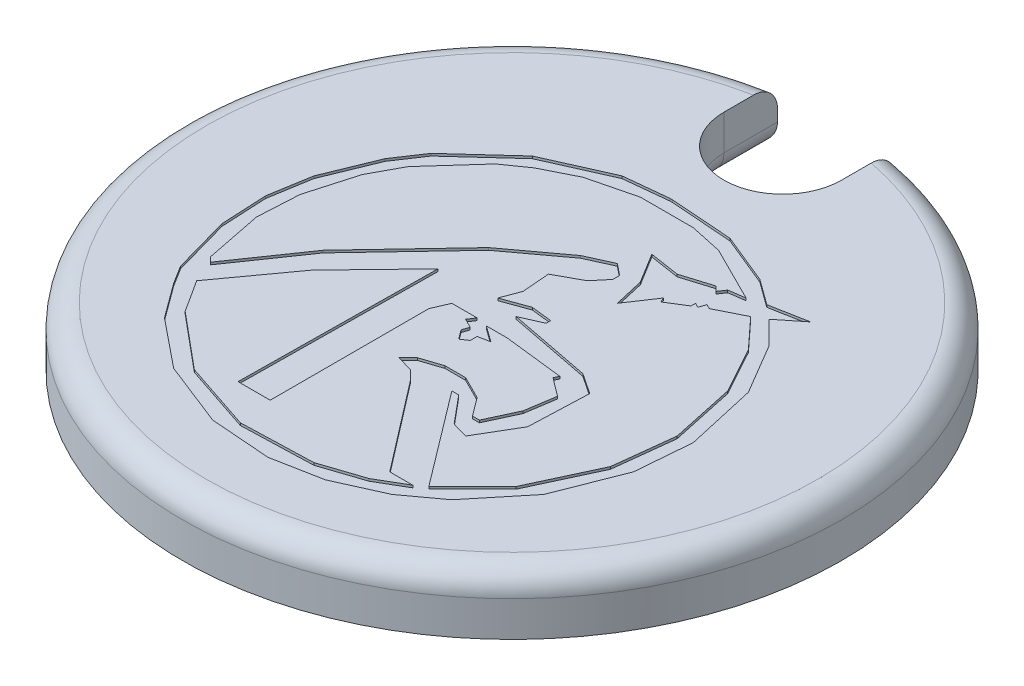
from build123d import *

# Parameters (mm, degrees)
SKETCH2_R               = 35.56
BOSS_EXTRUDE1_DEPTH     = 6.35
CUT_EXTRUDE2_DEPTH      = 1
CUT_EXTRUDE2_DEPTH_BACK = 7.35
FILLET2_R               = 2.54
BOSS_EXTRUDE5_DEPTH     = 5.334
CUT_EXTRUDE3_DEPTH      = 0.254
FILLET3_R               = 2.54


with BuildPart() as part:
    # Sketch2 → Boss-Extrude1 (new body)
    with BuildSketch(Plane(origin=(0, 0, 0), x_dir=(1, 0, 0), z_dir=(0, 1, 0))):
        Circle(SKETCH2_R)
    extrude(amount=BOSS_EXTRUDE1_DEPTH)

    # Sketch5 → Cut-Extrude2 (cut, two sides)
    with BuildSketch(Plane.XZ) as cut_extrude2_sk:
        with BuildLine():
            Line((6.35, -34.988442377), (6.35, -29.21))
            ThreePointArc((6.35, -29.21), (0, -22.86), (-6.35, -29.21))
            Line((-6.35, -29.21), (-6.35, -34.988442377))
            ThreePointArc((-6.35, -34.988442377), (0, -35.56), (6.35, -34.988442377))
        make_face()
    extrude(amount=CUT_EXTRUDE2_DEPTH, mode=Mode.SUBTRACT)
    extrude(cut_extrude2_sk.sketch, amount=-CUT_EXTRUDE2_DEPTH_BACK, mode=Mode.SUBTRACT)

    # Fillet2
    fillet2_edges = [part.edges().sort_by_distance(p)[0] for p in [
        (-6.35, 0, -32.099221189),
        (0, 0, -22.86),
        (6.35, 0, -32.099221189),
    ]]
    fillet(fillet2_edges, radius=FILLET2_R)

    # Sketch12 → Boss-Extrude5 (add)
    with BuildSketch(Plane(origin=(0, 6.35, 0), x_dir=(1, 0, 0), z_dir=(0, 1, 0))):
        Polygon((-23.011064279, -8.288364013), (-21.274736154, -14.489535888), (-20.034501779, -16.473910888), (-17.305986154, -20.194614013), (-12.097001779, -24.411410888), (-5.151689279, -27.139926513), (1.297529471, -27.636020263), (6.506513846, -26.643832763), (11.467451346, -24.411410888), (15.188154471, -21.682895263), (19.652998221, -16.225864013), (22.381513846, -9.280551513), (22.877607596, -3.327426513), (21.141279471, 4.362026612), (17.916670096, 9.819057862), (15.436201346, 12.299526612), (17.916670096, 14.283901612), (13.947920096, 13.539760987), (11.219404471, 15.524135987), (5.762373221, 17.756557862), (-0.934892404, 18.252651612), (-1.182939279, 18.252651612), (-5.895829904, 17.756557862), (-12.593095529, 14.779995362), (-18.298173654, 9.571010987), (-20.282548654, 6.594448487), (-22.514970529, 1.137417237), (-23.259111154, -3.327426513), align=None)
        Polygon((-13.833329904, -7.792270263), (-7.136168544, -0.855924569), (-7.384111154, -22.178989013), (-3.911454904, -22.178989013), (-3.911454904, -5.063754638), (-3.167314279, -3.327426513), (-0.438798654, -3.327426513), (-0.934892404, -4.071567138), (0.057295096, -4.567660888), (-0.190751779, -5.311801513), (0.553388846, -6.303989013), (1.297529471, -5.807895263), (1.297529471, -5.063754638), (2.537763846, -4.815707763), (0.801435721, -3.575473388), (3.033857596, -3.575473388), (9.483076346, -4.319614013), (9.235029471, -4.815707763), (11.219404471, -6.303989013), (10.723310721, -9.528598388), (9.235029471, -12.753207763), (8.490888846, -12.753207763), (7.002607596, -10.768832763), (4.522138846, -9.528598388), (2.289716971, -9.528598388), (0.057295096, -10.272739013), (-0.934892404, -11.264926513), (0.801435721, -11.761020263), (1.793623221, -12.753207763), (9.235029471, -22.427035888), (11.715498221, -22.427035888), (8.738935721, -24.163364013), (4.274091971, -25.651645263), (-3.415361154, -25.899692138), (-10.856767404, -23.419223388), (-16.809892404, -18.458285888), (-19.042314279, -14.985629638), align=None, mode=Mode.SUBTRACT)
        Polygon((-7.880204904, 15.524135987), (-2.919267404, 16.764370362), (-2.671220529, 16.764370362), (2.785810721, 16.764370362), (6.258466971, 16.020229737), (12.211591971, 13.043667237), (10.475263846, 12.795620362), (9.979170096, 12.051479737), (9.483076346, 12.547573487), (6.258466971, 11.555385987), (3.033857596, 12.051479737), (5.018232596, 8.826870362), (5.762373221, 5.602260987), (7.746748221, 8.578823487), (7.994795096, 8.082729737), (9.979170096, 9.322964112), (9.979170096, 9.819057862), (10.475263846, 9.571010987), (10.723310721, 10.315151612), (11.219404471, 10.067104737), (14.195966971, 11.555385987), (17.172529471, 8.330776612), (19.901045096, 3.369839112), (21.389326346, -3.575473388), (20.645185721, -10.024692138), (17.420576346, -16.970004638), (12.707685721, -21.682895263), (5.018232596, -11.512973388), (5.762373221, -11.512973388), (8.242841971, -14.489535888), (9.979170096, -14.985629638), (12.459638846, -10.768832763), (12.707685721, -4.319614013), (10.475263846, -2.831332763), (1.545576346, -1.095004638), (3.777998221, -0.102817138), (3.777998221, 0.393276612), (1.545576346, 0.641323487), (-1.182939279, -0.350864013), (-0.438798654, 1.633510987), (-0.686845529, 4.610073487), (2.041670096, 6.098354737), (3.281904471, 7.586635987), (3.281904471, 8.330776612), (2.041670096, 9.322964112), (-0.686845529, 8.082729737), (-6.391923654, 3.865932862), (-15.073564279, -5.311801513), (-20.034501779, -12.505160888), (-20.530595529, -12.009067138), (-21.770829904, -5.807895263), (-21.522783029, -1.343051513), (-20.034501779, 3.865932862), (-18.298173654, 7.090542237), (-13.833329904, 12.051479737), (-11.352861154, 13.787807862), align=None, mode=Mode.SUBTRACT)
        Polygon((-23.011064279, -8.288364013), (-21.274736154, -14.489535888), (-20.034501779, -16.473910888), (-17.305986154, -20.194614013), (-12.097001779, -24.411410888), (-5.151689279, -27.139926513), (1.297529471, -27.636020263), (6.506513846, -26.643832763), (11.467451346, -24.411410888), (15.188154471, -21.682895263), (19.652998221, -16.225864013), (22.381513846, -9.280551513), (22.877607596, -3.327426513), (21.141279471, 4.362026612), (17.916670096, 9.819057862), (15.436201346, 12.299526612), (17.916670096, 14.283901612), (13.947920096, 13.539760987), (11.219404471, 15.524135987), (5.762373221, 17.756557862), (-0.934892404, 18.252651612), (-1.182939279, 18.252651612), (-5.895829904, 17.756557862), (-12.593095529, 14.779995362), (-18.298173654, 9.571010987), (-20.282548654, 6.594448487), (-22.514970529, 1.137417237), (-23.259111154, -3.327426513), align=None)
        Polygon((-13.833329904, -7.792270263), (-7.136168544, -0.855924569), (-7.384111154, -22.178989013), (-3.911454904, -22.178989013), (-3.911454904, -5.063754638), (-3.167314279, -3.327426513), (-0.438798654, -3.327426513), (-0.934892404, -4.071567138), (0.057295096, -4.567660888), (-0.190751779, -5.311801513), (0.553388846, -6.303989013), (1.297529471, -5.807895263), (1.297529471, -5.063754638), (2.537763846, -4.815707763), (0.801435721, -3.575473388), (3.033857596, -3.575473388), (9.483076346, -4.319614013), (9.235029471, -4.815707763), (11.219404471, -6.303989013), (10.723310721, -9.528598388), (9.235029471, -12.753207763), (8.490888846, -12.753207763), (7.002607596, -10.768832763), (4.522138846, -9.528598388), (2.289716971, -9.528598388), (0.057295096, -10.272739013), (-0.934892404, -11.264926513), (0.801435721, -11.761020263), (1.793623221, -12.753207763), (9.235029471, -22.427035888), (11.715498221, -22.427035888), (8.738935721, -24.163364013), (4.274091971, -25.651645263), (-3.415361154, -25.899692138), (-10.856767404, -23.419223388), (-16.809892404, -18.458285888), (-19.042314279, -14.985629638), align=None, mode=Mode.SUBTRACT)
        Polygon((-7.880204904, 15.524135987), (-2.919267404, 16.764370362), (-2.671220529, 16.764370362), (2.785810721, 16.764370362), (6.258466971, 16.020229737), (12.211591971, 13.043667237), (10.475263846, 12.795620362), (9.979170096, 12.051479737), (9.483076346, 12.547573487), (6.258466971, 11.555385987), (3.033857596, 12.051479737), (5.018232596, 8.826870362), (5.762373221, 5.602260987), (7.746748221, 8.578823487), (7.994795096, 8.082729737), (9.979170096, 9.322964112), (9.979170096, 9.819057862), (10.475263846, 9.571010987), (10.723310721, 10.315151612), (11.219404471, 10.067104737), (14.195966971, 11.555385987), (17.172529471, 8.330776612), (19.901045096, 3.369839112), (21.389326346, -3.575473388), (20.645185721, -10.024692138), (17.420576346, -16.970004638), (12.707685721, -21.682895263), (5.018232596, -11.512973388), (5.762373221, -11.512973388), (8.242841971, -14.489535888), (9.979170096, -14.985629638), (12.459638846, -10.768832763), (12.707685721, -4.319614013), (10.475263846, -2.831332763), (1.545576346, -1.095004638), (3.777998221, -0.102817138), (3.777998221, 0.393276612), (1.545576346, 0.641323487), (-1.182939279, -0.350864013), (-0.438798654, 1.633510987), (-0.686845529, 4.610073487), (2.041670096, 6.098354737), (3.281904471, 7.586635987), (3.281904471, 8.330776612), (2.041670096, 9.322964112), (-0.686845529, 8.082729737), (-6.391923654, 3.865932862), (-15.073564279, -5.311801513), (-20.034501779, -12.505160888), (-20.530595529, -12.009067138), (-21.770829904, -5.807895263), (-21.522783029, -1.343051513), (-20.034501779, 3.865932862), (-18.298173654, 7.090542237), (-13.833329904, 12.051479737), (-11.352861154, 13.787807862), align=None, mode=Mode.SUBTRACT)
        Polygon((-23.011064279, -8.288364013), (-21.274736154, -14.489535888), (-20.034501779, -16.473910888), (-17.305986154, -20.194614013), (-12.097001779, -24.411410888), (-5.151689279, -27.139926513), (1.297529471, -27.636020263), (6.506513846, -26.643832763), (11.467451346, -24.411410888), (15.188154471, -21.682895263), (19.652998221, -16.225864013), (22.381513846, -9.280551513), (22.877607596, -3.327426513), (21.141279471, 4.362026612), (17.916670096, 9.819057862), (15.436201346, 12.299526612), (17.916670096, 14.283901612), (13.947920096, 13.539760987), (11.219404471, 15.524135987), (5.762373221, 17.756557862), (-0.934892404, 18.252651612), (-1.182939279, 18.252651612), (-5.895829904, 17.756557862), (-12.593095529, 14.779995362), (-18.298173654, 9.571010987), (-20.282548654, 6.594448487), (-22.514970529, 1.137417237), (-23.259111154, -3.327426513), align=None)
        Polygon((-13.833329904, -7.792270263), (-7.136168544, -0.855924569), (-7.384111154, -22.178989013), (-3.911454904, -22.178989013), (-3.911454904, -5.063754638), (-3.167314279, -3.327426513), (-0.438798654, -3.327426513), (-0.934892404, -4.071567138), (0.057295096, -4.567660888), (-0.190751779, -5.311801513), (0.553388846, -6.303989013), (1.297529471, -5.807895263), (1.297529471, -5.063754638), (2.537763846, -4.815707763), (0.801435721, -3.575473388), (3.033857596, -3.575473388), (9.483076346, -4.319614013), (9.235029471, -4.815707763), (11.219404471, -6.303989013), (10.723310721, -9.528598388), (9.235029471, -12.753207763), (8.490888846, -12.753207763), (7.002607596, -10.768832763), (4.522138846, -9.528598388), (2.289716971, -9.528598388), (0.057295096, -10.272739013), (-0.934892404, -11.264926513), (0.801435721, -11.761020263), (1.793623221, -12.753207763), (9.235029471, -22.427035888), (11.715498221, -22.427035888), (8.738935721, -24.163364013), (4.274091971, -25.651645263), (-3.415361154, -25.899692138), (-10.856767404, -23.419223388), (-16.809892404, -18.458285888), (-19.042314279, -14.985629638), align=None, mode=Mode.SUBTRACT)
        Polygon((-7.880204904, 15.524135987), (-2.919267404, 16.764370362), (-2.671220529, 16.764370362), (2.785810721, 16.764370362), (6.258466971, 16.020229737), (12.211591971, 13.043667237), (10.475263846, 12.795620362), (9.979170096, 12.051479737), (9.483076346, 12.547573487), (6.258466971, 11.555385987), (3.033857596, 12.051479737), (5.018232596, 8.826870362), (5.762373221, 5.602260987), (7.746748221, 8.578823487), (7.994795096, 8.082729737), (9.979170096, 9.322964112), (9.979170096, 9.819057862), (10.475263846, 9.571010987), (10.723310721, 10.315151612), (11.219404471, 10.067104737), (14.195966971, 11.555385987), (17.172529471, 8.330776612), (19.901045096, 3.369839112), (21.389326346, -3.575473388), (20.645185721, -10.024692138), (17.420576346, -16.970004638), (12.707685721, -21.682895263), (5.018232596, -11.512973388), (5.762373221, -11.512973388), (8.242841971, -14.489535888), (9.979170096, -14.985629638), (12.459638846, -10.768832763), (12.707685721, -4.319614013), (10.475263846, -2.831332763), (1.545576346, -1.095004638), (3.777998221, -0.102817138), (3.777998221, 0.393276612), (1.545576346, 0.641323487), (-1.182939279, -0.350864013), (-0.438798654, 1.633510987), (-0.686845529, 4.610073487), (2.041670096, 6.098354737), (3.281904471, 7.586635987), (3.281904471, 8.330776612), (2.041670096, 9.322964112), (-0.686845529, 8.082729737), (-6.391923654, 3.865932862), (-15.073564279, -5.311801513), (-20.034501779, -12.505160888), (-20.530595529, -12.009067138), (-21.770829904, -5.807895263), (-21.522783029, -1.343051513), (-20.034501779, 3.865932862), (-18.298173654, 7.090542237), (-13.833329904, 12.051479737), (-11.352861154, 13.787807862), align=None, mode=Mode.SUBTRACT)
        Polygon((-23.011064279, -8.288364013), (-21.274736154, -14.489535888), (-20.034501779, -16.473910888), (-17.305986154, -20.194614013), (-12.097001779, -24.411410888), (-5.151689279, -27.139926513), (1.297529471, -27.636020263), (6.506513846, -26.643832763), (11.467451346, -24.411410888), (15.188154471, -21.682895263), (19.652998221, -16.225864013), (22.381513846, -9.280551513), (22.877607596, -3.327426513), (21.141279471, 4.362026612), (17.916670096, 9.819057862), (15.436201346, 12.299526612), (17.916670096, 14.283901612), (13.947920096, 13.539760987), (11.219404471, 15.524135987), (5.762373221, 17.756557862), (-0.934892404, 18.252651612), (-1.182939279, 18.252651612), (-5.895829904, 17.756557862), (-12.593095529, 14.779995362), (-18.298173654, 9.571010987), (-20.282548654, 6.594448487), (-22.514970529, 1.137417237), (-23.259111154, -3.327426513), align=None)
        Polygon((-13.833329904, -7.792270263), (-7.136168544, -0.855924569), (-7.384111154, -22.178989013), (-3.911454904, -22.178989013), (-3.911454904, -5.063754638), (-3.167314279, -3.327426513), (-0.438798654, -3.327426513), (-0.934892404, -4.071567138), (0.057295096, -4.567660888), (-0.190751779, -5.311801513), (0.553388846, -6.303989013), (1.297529471, -5.807895263), (1.297529471, -5.063754638), (2.537763846, -4.815707763), (0.801435721, -3.575473388), (3.033857596, -3.575473388), (9.483076346, -4.319614013), (9.235029471, -4.815707763), (11.219404471, -6.303989013), (10.723310721, -9.528598388), (9.235029471, -12.753207763), (8.490888846, -12.753207763), (7.002607596, -10.768832763), (4.522138846, -9.528598388), (2.289716971, -9.528598388), (0.057295096, -10.272739013), (-0.934892404, -11.264926513), (0.801435721, -11.761020263), (1.793623221, -12.753207763), (9.235029471, -22.427035888), (11.715498221, -22.427035888), (8.738935721, -24.163364013), (4.274091971, -25.651645263), (-3.415361154, -25.899692138), (-10.856767404, -23.419223388), (-16.809892404, -18.458285888), (-19.042314279, -14.985629638), align=None, mode=Mode.SUBTRACT)
        Polygon((-7.880204904, 15.524135987), (-2.919267404, 16.764370362), (-2.671220529, 16.764370362), (2.785810721, 16.764370362), (6.258466971, 16.020229737), (12.211591971, 13.043667237), (10.475263846, 12.795620362), (9.979170096, 12.051479737), (9.483076346, 12.547573487), (6.258466971, 11.555385987), (3.033857596, 12.051479737), (5.018232596, 8.826870362), (5.762373221, 5.602260987), (7.746748221, 8.578823487), (7.994795096, 8.082729737), (9.979170096, 9.322964112), (9.979170096, 9.819057862), (10.475263846, 9.571010987), (10.723310721, 10.315151612), (11.219404471, 10.067104737), (14.195966971, 11.555385987), (17.172529471, 8.330776612), (19.901045096, 3.369839112), (21.389326346, -3.575473388), (20.645185721, -10.024692138), (17.420576346, -16.970004638), (12.707685721, -21.682895263), (5.018232596, -11.512973388), (5.762373221, -11.512973388), (8.242841971, -14.489535888), (9.979170096, -14.985629638), (12.459638846, -10.768832763), (12.707685721, -4.319614013), (10.475263846, -2.831332763), (1.545576346, -1.095004638), (3.777998221, -0.102817138), (3.777998221, 0.393276612), (1.545576346, 0.641323487), (-1.182939279, -0.350864013), (-0.438798654, 1.633510987), (-0.686845529, 4.610073487), (2.041670096, 6.098354737), (3.281904471, 7.586635987), (3.281904471, 8.330776612), (2.041670096, 9.322964112), (-0.686845529, 8.082729737), (-6.391923654, 3.865932862), (-15.073564279, -5.311801513), (-20.034501779, -12.505160888), (-20.530595529, -12.009067138), (-21.770829904, -5.807895263), (-21.522783029, -1.343051513), (-20.034501779, 3.865932862), (-18.298173654, 7.090542237), (-13.833329904, 12.051479737), (-11.352861154, 13.787807862), align=None, mode=Mode.SUBTRACT)
        Polygon((-2.671220529, 16.764370362), (-2.919267404, 16.764370362), (-7.880204904, 15.524135987), (-11.352861154, 13.787807862), (-13.833329904, 12.051479737), (-18.298173654, 7.090542237), (-20.034501779, 3.865932862), (-21.522783029, -1.343051513), (-21.770829904, -5.807895263), (-20.530595529, -12.009067138), (-20.034501779, -12.505160888), (-15.073564279, -5.311801513), (-6.391923654, 3.865932862), (-0.686845529, 8.082729737), (2.041670096, 9.322964112), (3.281904471, 8.330776612), (3.281904471, 7.586635987), (2.041670096, 6.098354737), (-0.686845529, 4.610073487), (-0.438798654, 1.633510987), (-1.182939279, -0.350864013), (1.545576346, 0.641323487), (3.777998221, 0.393276612), (3.777998221, -0.102817138), (1.545576346, -1.095004638), (10.475263846, -2.831332763), (12.707685721, -4.319614013), (12.459638846, -10.768832763), (9.979170096, -14.985629638), (8.242841971, -14.489535888), (5.762373221, -11.512973388), (5.018232596, -11.512973388), (12.707685721, -21.682895263), (17.420576346, -16.970004638), (20.645185721, -10.024692138), (21.389326346, -3.575473388), (19.901045096, 3.369839112), (17.172529471, 8.330776612), (14.195966971, 11.555385987), (11.219404471, 10.067104737), (10.723310721, 10.315151612), (10.475263846, 9.571010987), (9.979170096, 9.819057862), (9.979170096, 9.322964112), (7.994795096, 8.082729737), (7.746748221, 8.578823487), (5.762373221, 5.602260987), (5.018232596, 8.826870362), (3.033857596, 12.051479737), (6.258466971, 11.555385987), (9.483076346, 12.547573487), (9.979170096, 12.051479737), (10.475263846, 12.795620362), (12.211591971, 13.043667237), (6.258466971, 16.020229737), (2.785810721, 16.764370362), align=None)
        Polygon((-2.671220529, 16.764370362), (-2.919267404, 16.764370362), (-7.880204904, 15.524135987), (-11.352861154, 13.787807862), (-13.833329904, 12.051479737), (-18.298173654, 7.090542237), (-20.034501779, 3.865932862), (-21.522783029, -1.343051513), (-21.770829904, -5.807895263), (-20.530595529, -12.009067138), (-20.034501779, -12.505160888), (-15.073564279, -5.311801513), (-6.391923654, 3.865932862), (-0.686845529, 8.082729737), (2.041670096, 9.322964112), (3.281904471, 8.330776612), (3.281904471, 7.586635987), (2.041670096, 6.098354737), (-0.686845529, 4.610073487), (-0.438798654, 1.633510987), (-1.182939279, -0.350864013), (1.545576346, 0.641323487), (3.777998221, 0.393276612), (3.777998221, -0.102817138), (1.545576346, -1.095004638), (10.475263846, -2.831332763), (12.707685721, -4.319614013), (12.459638846, -10.768832763), (9.979170096, -14.985629638), (8.242841971, -14.489535888), (5.762373221, -11.512973388), (5.018232596, -11.512973388), (12.707685721, -21.682895263), (17.420576346, -16.970004638), (20.645185721, -10.024692138), (21.389326346, -3.575473388), (19.901045096, 3.369839112), (17.172529471, 8.330776612), (14.195966971, 11.555385987), (11.219404471, 10.067104737), (10.723310721, 10.315151612), (10.475263846, 9.571010987), (9.979170096, 9.819057862), (9.979170096, 9.322964112), (7.994795096, 8.082729737), (7.746748221, 8.578823487), (5.762373221, 5.602260987), (5.018232596, 8.826870362), (3.033857596, 12.051479737), (6.258466971, 11.555385987), (9.483076346, 12.547573487), (9.979170096, 12.051479737), (10.475263846, 12.795620362), (12.211591971, 13.043667237), (6.258466971, 16.020229737), (2.785810721, 16.764370362), align=None)
    extrude(amount=-BOSS_EXTRUDE5_DEPTH)

    # Sketch12_4 → Cut-Extrude3 (cut)
    with BuildSketch(Plane(origin=(0, 6.35, 0), x_dir=(1, 0, 0), z_dir=(0, 1, 0))):
        Polygon((-23.011064279, -8.288364013), (-21.274736154, -14.489535888), (-20.034501779, -16.473910888), (-17.305986154, -20.194614013), (-12.097001779, -24.411410888), (-5.151689279, -27.139926513), (1.297529471, -27.636020263), (6.506513846, -26.643832763), (11.467451346, -24.411410888), (15.188154471, -21.682895263), (19.652998221, -16.225864013), (22.381513846, -9.280551513), (22.877607596, -3.327426513), (21.141279471, 4.362026612), (17.916670096, 9.819057862), (15.436201346, 12.299526612), (17.916670096, 14.283901612), (13.947920096, 13.539760987), (11.219404471, 15.524135987), (5.762373221, 17.756557862), (-0.934892404, 18.252651612), (-1.182939279, 18.252651612), (-5.895829904, 17.756557862), (-12.593095529, 14.779995362), (-18.298173654, 9.571010987), (-20.282548654, 6.594448487), (-22.514970529, 1.137417237), (-23.259111154, -3.327426513), align=None)
        Polygon((-13.833329904, -7.792270263), (-7.136168544, -0.855924569), (-7.384111154, -22.178989013), (-3.911454904, -22.178989013), (-3.911454904, -5.063754638), (-3.167314279, -3.327426513), (-0.438798654, -3.327426513), (-0.934892404, -4.071567138), (0.057295096, -4.567660888), (-0.190751779, -5.311801513), (0.553388846, -6.303989013), (1.297529471, -5.807895263), (1.297529471, -5.063754638), (2.537763846, -4.815707763), (0.801435721, -3.575473388), (3.033857596, -3.575473388), (9.483076346, -4.319614013), (9.235029471, -4.815707763), (11.219404471, -6.303989013), (10.723310721, -9.528598388), (9.235029471, -12.753207763), (8.490888846, -12.753207763), (7.002607596, -10.768832763), (4.522138846, -9.528598388), (2.289716971, -9.528598388), (0.057295096, -10.272739013), (-0.934892404, -11.264926513), (0.801435721, -11.761020263), (1.793623221, -12.753207763), (9.235029471, -22.427035888), (11.715498221, -22.427035888), (8.738935721, -24.163364013), (4.274091971, -25.651645263), (-3.415361154, -25.899692138), (-10.856767404, -23.419223388), (-16.809892404, -18.458285888), (-19.042314279, -14.985629638), align=None, mode=Mode.SUBTRACT)
        Polygon((-7.880204904, 15.524135987), (-2.919267404, 16.764370362), (-2.671220529, 16.764370362), (2.785810721, 16.764370362), (6.258466971, 16.020229737), (12.211591971, 13.043667237), (10.475263846, 12.795620362), (9.979170096, 12.051479737), (9.483076346, 12.547573487), (6.258466971, 11.555385987), (3.033857596, 12.051479737), (5.018232596, 8.826870362), (5.762373221, 5.602260987), (7.746748221, 8.578823487), (7.994795096, 8.082729737), (9.979170096, 9.322964112), (9.979170096, 9.819057862), (10.475263846, 9.571010987), (10.723310721, 10.315151612), (11.219404471, 10.067104737), (14.195966971, 11.555385987), (17.172529471, 8.330776612), (19.901045096, 3.369839112), (21.389326346, -3.575473388), (20.645185721, -10.024692138), (17.420576346, -16.970004638), (12.707685721, -21.682895263), (5.018232596, -11.512973388), (5.762373221, -11.512973388), (8.242841971, -14.489535888), (9.979170096, -14.985629638), (12.459638846, -10.768832763), (12.707685721, -4.319614013), (10.475263846, -2.831332763), (1.545576346, -1.095004638), (3.777998221, -0.102817138), (3.777998221, 0.393276612), (1.545576346, 0.641323487), (-1.182939279, -0.350864013), (-0.438798654, 1.633510987), (-0.686845529, 4.610073487), (2.041670096, 6.098354737), (3.281904471, 7.586635987), (3.281904471, 8.330776612), (2.041670096, 9.322964112), (-0.686845529, 8.082729737), (-6.391923654, 3.865932862), (-15.073564279, -5.311801513), (-20.034501779, -12.505160888), (-20.530595529, -12.009067138), (-21.770829904, -5.807895263), (-21.522783029, -1.343051513), (-20.034501779, 3.865932862), (-18.298173654, 7.090542237), (-13.833329904, 12.051479737), (-11.352861154, 13.787807862), align=None, mode=Mode.SUBTRACT)
    extrude(amount=-CUT_EXTRUDE3_DEPTH, mode=Mode.SUBTRACT)

    # Fillet3
    fillet3_edges = [part.edges().sort_by_distance(p)[0] for p in [
        (0, 6.35, 35.56),
    ]]
    fillet(fillet3_edges, radius=FILLET3_R)


solid = part.part
